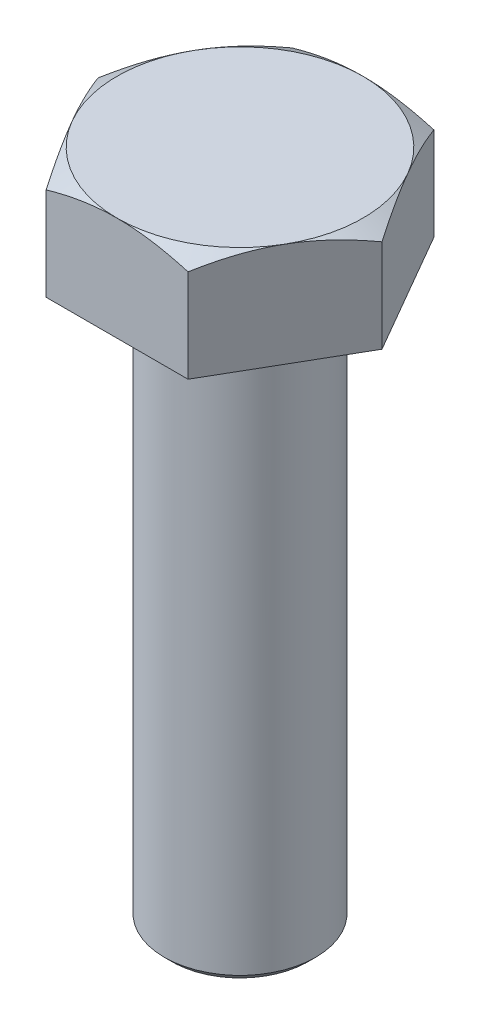
from build123d import *

# Parameters (mm, degrees)
BOSS_EXTRUDE1_DEPTH = 5.5
SKETCH2_R           = 4
BOSS_EXTRUDE2_DEPTH = 30
FILLET1_R           = 0.4
CHAMFER1_SIZE       = 0.4


with BuildPart() as part:
    # Sketch1 → Boss-Extrude1 (new body)
    with BuildSketch(Plane(origin=(0, 0, 0), x_dir=(1, 0, 0), z_dir=(0, 1, 0))):
        Polygon((-3.75277675, -6.5), (3.75277675, -6.5), (7.505553499, 0), (3.75277675, 6.5), (-3.75277675, 6.5), (-7.505553499, 0), align=None)
    extrude(amount=BOSS_EXTRUDE1_DEPTH)

    # Sketch2 → Boss-Extrude2 (add)
    with BuildSketch(Plane.XZ):
        Circle(SKETCH2_R)
    extrude(amount=BOSS_EXTRUDE2_DEPTH)

    # Fillet1
    fillet1_edges = [part.edges().sort_by_distance(p)[0] for p in [
        (-4, 0, 0),
    ]]
    fillet(fillet1_edges, radius=FILLET1_R)

    # Chamfer1
    chamfer1_edges = [part.edges().sort_by_distance(p)[0] for p in [
        (-4, -30, 0),
    ]]
    chamfer(chamfer1_edges, length=CHAMFER1_SIZE)

    # Sketch3 → Cut-Revolve1 (revolve, cut)
    with BuildSketch(Plane(origin=(0, 0, 0), x_dir=(0, 0, -1), z_dir=(1, 0, 0))):
        Polygon((6.5, 5.5), (16.319077894, -0.169047265), (16.319077894, 5.5), align=None)
    revolve(axis=Axis((0, 0, 0), (0, 1, 0)), mode=Mode.SUBTRACT)


solid = part.part
